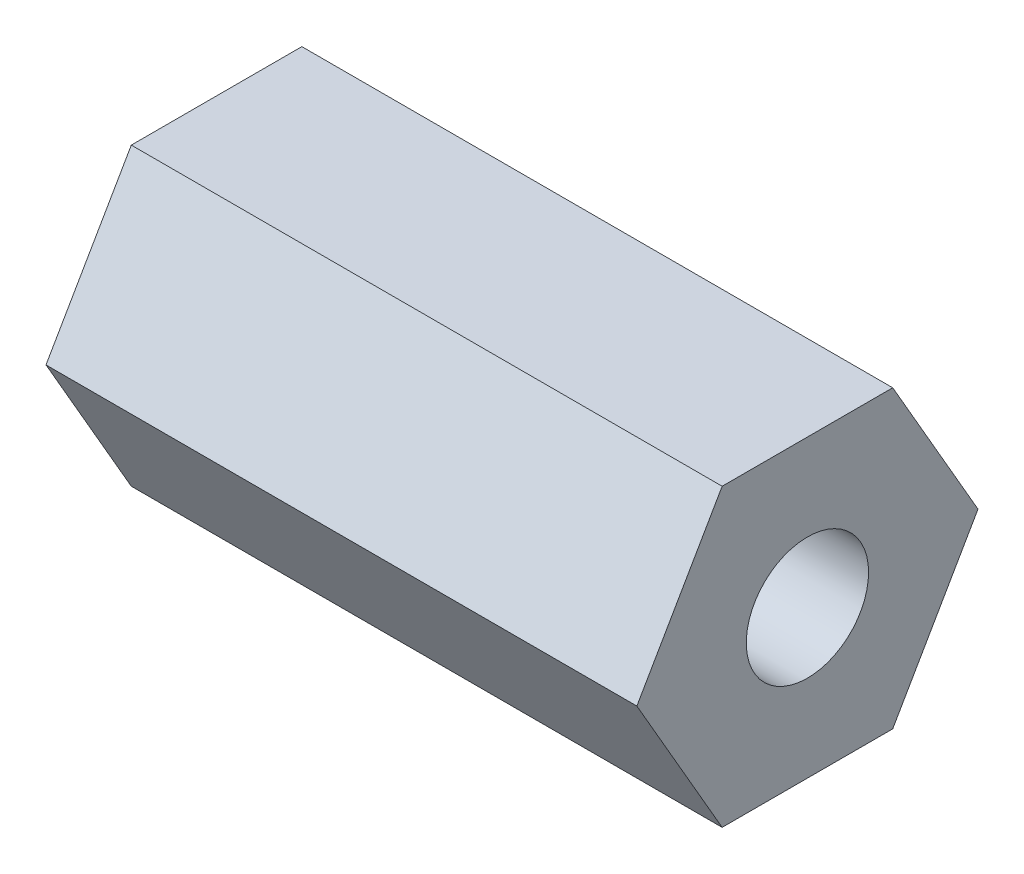
from build123d import *

# Parameters (mm, degrees)
SKETCH1_R           = 2.6289
BOSS_EXTRUDE1_DEPTH = 25.4


with BuildPart() as part:
    # Sketch1 → Boss-Extrude1 (new body)
    with BuildSketch(Plane(origin=(0, 0, 0), x_dir=(0, 0, -1), z_dir=(1, 0, 0))):
        Polygon((3.666174209, -6.35), (7.332348419, 0), (3.666174209, 6.35), (-3.666174209, 6.35), (-7.332348419, 0), (-3.666174209, -6.35), align=None)
        Circle(SKETCH1_R, mode=Mode.SUBTRACT)
    extrude(amount=BOSS_EXTRUDE1_DEPTH)


solid = part.part
